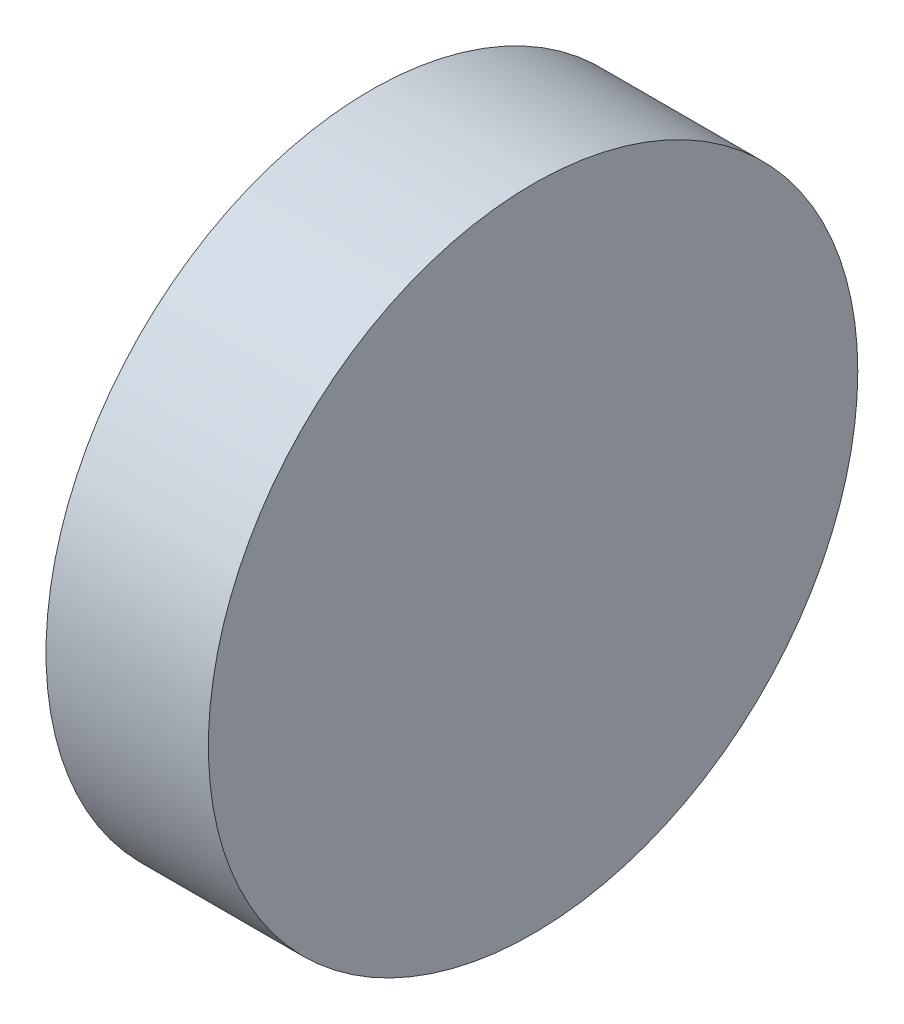
from build123d import *

# Parameters (mm, degrees)
SKETCH1_R           = 152.4
BOSS_EXTRUDE1_DEPTH = 76.2


with BuildPart() as part:
    # Sketch1 → Boss-Extrude1 (new body)
    with BuildSketch(Plane(origin=(0, 0, 0), x_dir=(0, 0, -1), z_dir=(1, 0, 0))):
        Circle(SKETCH1_R)
    extrude(amount=BOSS_EXTRUDE1_DEPTH)


solid = part.part
